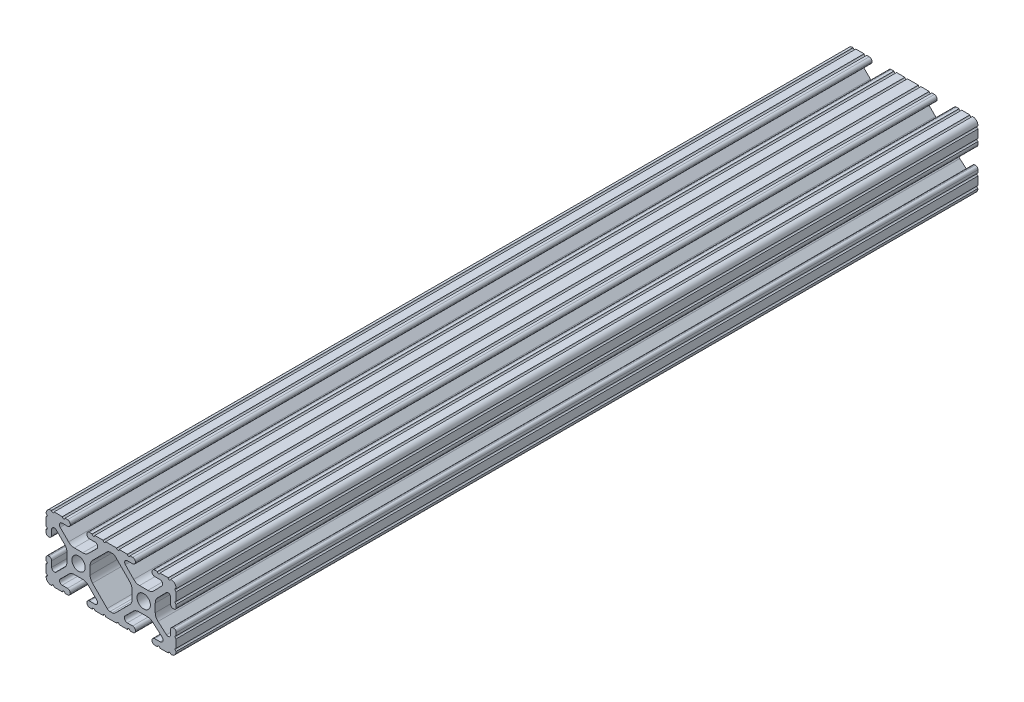
from build123d import *

# Parameters (mm, degrees)
SKETCH1_R           = 2.6035
BOSS_EXTRUDE1_DEPTH = 156.35


with BuildPart() as part:
    # Sketch1 → Boss-Extrude1 (new body, symmetric)
    with BuildSketch(Plane.XY):
        with BuildLine():
            Line((18.01710265, 12.7), (16.98745015, 12.7))
            ThreePointArc((16.98745015, 12.7), (16.245730386, 12.392769614), (15.9385, 11.65104985))
            Line((15.9385, 11.65104985), (15.9385, 11.53922))
            ThreePointArc((15.9385, 11.53922), (16.245750844, 10.797450844), (16.98752, 10.4902))
            Line((16.98752, 10.4902), (19.116384363, 10.4902))
            ThreePointArc((19.116384363, 10.4902), (20.052502933, 9.869096983), (19.844087081, 8.765172272))
            Line((19.844087081, 8.765172272), (16.618993479, 5.455112286))
            ThreePointArc((16.618993479, 5.455112286), (15.578994274, 4.745442459), (14.344932584, 4.4958))
            Line((14.344932584, 4.4958), (11.083317835, 4.4958))
            ThreePointArc((11.083317835, 4.4958), (9.854330953, 4.743306833), (8.816955189, 5.447238587))
            Line((8.816955189, 5.447238587), (5.564154119, 8.762652677))
            ThreePointArc((5.564154119, 8.762652677), (5.352591412, 9.867473037), (6.289393385, 10.4902))
            Line((6.289393385, 10.4902), (8.41248, 10.4902))
            ThreePointArc((8.41248, 10.4902), (9.154249156, 10.797450844), (9.4615, 11.53922))
            Line((9.4615, 11.53922), (9.4615, 11.65104985))
            ThreePointArc((9.4615, 11.65104985), (9.154269614, 12.392769614), (8.41254985, 12.7))
            Line((8.41254985, 12.7), (7.38288465, 12.7))
            ThreePointArc((7.38288465, 12.7), (6.87488465, 12.192), (6.36688465, 12.7))
            Line((6.36688465, 12.7), (3.14958095, 12.7))
            ThreePointArc((3.14958095, 12.7), (2.64158095, 12.192), (2.13358095, 12.7))
            Line((2.13358095, 12.7), (-2.13358095, 12.7))
            ThreePointArc((-2.13358095, 12.7), (-2.64158095, 12.192), (-3.14958095, 12.7))
            Line((-3.14958095, 12.7), (-6.36689735, 12.7))
            ThreePointArc((-6.36689735, 12.7), (-6.87489735, 12.192), (-7.38289735, 12.7))
            Line((-7.38289735, 12.7), (-8.41254985, 12.7))
            ThreePointArc((-8.41254985, 12.7), (-9.154269614, 12.392769614), (-9.4615, 11.65104985))
            Line((-9.4615, 11.65104985), (-9.4615, 11.53922))
            ThreePointArc((-9.4615, 11.53922), (-9.154249156, 10.797450844), (-8.41248, 10.4902))
            Line((-8.41248, 10.4902), (-6.283641037, 10.4902))
            ThreePointArc((-6.283641037, 10.4902), (-5.297291557, 9.829633109), (-5.532576693, 8.666071843))
            Line((-5.532576693, 8.666071843), (-8.809985098, 5.416263103))
            ThreePointArc((-8.809985098, 5.416263103), (-9.836720513, 4.734920264), (-11.045536121, 4.4958))
            Line((-11.045536121, 4.4958), (-14.354463879, 4.4958))
            ThreePointArc((-14.354463879, 4.4958), (-15.563279487, 4.734920264), (-16.590014902, 5.416263103))
            Line((-16.590014902, 5.416263103), (-19.867423307, 8.666071843))
            ThreePointArc((-19.867423307, 8.666071843), (-20.102708443, 9.829633109), (-19.116358963, 10.4902))
            Line((-19.116358963, 10.4902), (-16.98752, 10.4902))
            ThreePointArc((-16.98752, 10.4902), (-16.245750844, 10.797450844), (-15.9385, 11.53922))
            Line((-15.9385, 11.53922), (-15.9385, 11.65104985))
            ThreePointArc((-15.9385, 11.65104985), (-16.245730386, 12.392769614), (-16.98745015, 12.7))
            Line((-16.98745015, 12.7), (-18.01711535, 12.7))
            ThreePointArc((-18.01711535, 12.7), (-18.52511535, 12.192), (-19.03311535, 12.7))
            Line((-19.03311535, 12.7), (-22.2504, 12.7))
            ThreePointArc((-22.2504, 12.7), (-22.758323491, 12.192000006), (-23.266399977, 12.699846982))
            ThreePointArc((-23.266399977, 12.699846982), (-24.782522516, 12.082522516), (-25.399846982, 10.566399977))
            ThreePointArc((-25.399846982, 10.566399977), (-24.892000006, 10.058323491), (-25.4, 9.5504))
            Line((-25.4, 9.5504), (-25.4, 6.3330836))
            ThreePointArc((-25.4, 6.3330836), (-24.892, 5.8250836), (-25.4, 5.3170836))
            Line((-25.4, 5.3170836), (-25.4, 4.237520184))
            ThreePointArc((-25.4, 4.237520184), (-25.107393763, 3.531106237), (-24.400979816, 3.2385))
            Line((-24.400979816, 3.2385), (-24.23922, 3.2385))
            ThreePointArc((-24.23922, 3.2385), (-23.497450844, 3.545750844), (-23.1902, 4.28752))
            Line((-23.1902, 4.28752), (-23.1902, 6.334741132))
            ThreePointArc((-23.1902, 6.334741132), (-22.556026952, 7.286023527), (-21.434002553, 7.066535717))
            Line((-21.434002553, 7.066535717), (-18.147950853, 3.808156468))
            ThreePointArc((-18.147950853, 3.808156468), (-17.452759693, 2.774838327), (-17.208501877, 1.553619571))
            Line((-17.208501877, 1.553619571), (-17.208501877, -1.695179196))
            ThreePointArc((-17.208501877, -1.695179196), (-17.450738657, -2.911536421), (-18.140486065, -3.942289578))
            Line((-18.140486065, -3.942289578), (-21.431579576, -7.227386226))
            ThreePointArc((-21.431579576, -7.227386226), (-22.55444896, -7.449940594), (-23.1902, -6.498002195))
            Line((-23.1902, -6.498002195), (-23.1902, -4.28752))
            ThreePointArc((-23.1902, -4.28752), (-23.497450844, -3.545750844), (-24.23922, -3.2385))
            Line((-24.23922, -3.2385), (-24.35098, -3.2385))
            ThreePointArc((-24.35098, -3.2385), (-25.092749156, -3.545750844), (-25.4, -4.28752))
            Line((-25.4, -4.28752), (-25.4, -5.3171344))
            ThreePointArc((-25.4, -5.3171344), (-24.892, -5.8251344), (-25.4, -6.3331344))
            Line((-25.4, -6.3331344), (-25.4, -9.5504))
            ThreePointArc((-25.4, -9.5504), (-24.892000006, -10.058323491), (-25.399846982, -10.566399977))
            ThreePointArc((-25.399846982, -10.566399977), (-24.782522516, -12.082522516), (-23.266399977, -12.699846982))
            ThreePointArc((-23.266399977, -12.699846982), (-22.758323491, -12.192000006), (-22.2504, -12.7))
            Line((-22.2504, -12.7), (-19.03308995, -12.7))
            ThreePointArc((-19.03308995, -12.7), (-18.52508995, -12.192), (-18.01708995, -12.7))
            Line((-18.01708995, -12.7), (-16.9874692, -12.7))
            ThreePointArc((-16.9874692, -12.7), (-16.245700044, -12.392749156), (-15.9384492, -11.65098))
            Line((-15.9384492, -11.65098), (-15.9384492, -11.53922))
            ThreePointArc((-15.9384492, -11.53922), (-16.245700044, -10.797450844), (-16.9874692, -10.4902))
            Line((-16.9874692, -10.4902), (-19.116358963, -10.4902))
            ThreePointArc((-19.116358963, -10.4902), (-20.055197748, -9.862578342), (-19.834124023, -8.755124678))
            Line((-19.834124023, -8.755124678), (-16.49660751, -5.423689618))
            ThreePointArc((-16.49660751, -5.423689618), (-15.467274017, -4.736928798), (-14.253591699, -4.4958))
            Line((-14.253591699, -4.4958), (-11.146408301, -4.4958))
            ThreePointArc((-11.146408301, -4.4958), (-9.932725983, -4.736928798), (-8.90339249, -5.423689618))
            Line((-8.90339249, -5.423689618), (-5.565875977, -8.755124678))
            ThreePointArc((-5.565875977, -8.755124678), (-5.344802252, -9.862578342), (-6.283641037, -10.4902))
            Line((-6.283641037, -10.4902), (-8.4125308, -10.4902))
            ThreePointArc((-8.4125308, -10.4902), (-9.154299956, -10.797450844), (-9.4615508, -11.53922))
            Line((-9.4615508, -11.53922), (-9.4615508, -11.65098))
            ThreePointArc((-9.4615508, -11.65098), (-9.154299956, -12.392749156), (-8.4125308, -12.7))
            Line((-8.4125308, -12.7), (-7.38287195, -12.7))
            ThreePointArc((-7.38287195, -12.7), (-6.87487195, -12.192), (-6.36687195, -12.7))
            Line((-6.36687195, -12.7), (-3.14960635, -12.7))
            ThreePointArc((-3.14960635, -12.7), (-2.64160635, -12.192), (-2.13360635, -12.7))
            Line((-2.13360635, -12.7), (2.13360635, -12.7))
            ThreePointArc((2.13360635, -12.7), (2.64159365, -12.1920127), (3.14958095, -12.7))
            Line((3.14958095, -12.7), (6.36691005, -12.7))
            ThreePointArc((6.36691005, -12.7), (6.87491005, -12.192), (7.38291005, -12.7))
            Line((7.38291005, -12.7), (8.4125308, -12.7))
            ThreePointArc((8.4125308, -12.7), (9.154299956, -12.392749156), (9.4615508, -11.65098))
            Line((9.4615508, -11.65098), (9.4615508, -11.53922))
            ThreePointArc((9.4615508, -11.53922), (9.154299956, -10.797450844), (8.4125308, -10.4902))
            Line((8.4125308, -10.4902), (6.289393385, -10.4902))
            ThreePointArc((6.289393385, -10.4902), (5.231590322, -9.783049717), (5.480677245, -8.535265862))
            Line((5.480677245, -8.535265862), (8.597933595, -5.423689618))
            ThreePointArc((8.597933595, -5.423689618), (9.627267088, -4.736928798), (10.840949406, -4.4958))
            Line((10.840949406, -4.4958), (14.102564155, -4.4958))
            ThreePointArc((14.102564155, -4.4958), (15.215927525, -4.697410182), (16.187895372, -5.276636531))
            Line((16.187895372, -5.276636531), (19.868247549, -8.482246082))
            ThreePointArc((19.868247549, -8.482246082), (20.188435806, -9.746879864), (19.116384363, -10.4902))
            Line((19.116384363, -10.4902), (16.9874692, -10.4902))
            ThreePointArc((16.9874692, -10.4902), (16.245700044, -10.797450844), (15.9384492, -11.53922))
            Line((15.9384492, -11.53922), (15.9384492, -11.65098))
            ThreePointArc((15.9384492, -11.65098), (16.245700044, -12.392749156), (16.9874692, -12.7))
            Line((16.9874692, -12.7), (18.01710265, -12.7))
            ThreePointArc((18.01710265, -12.7), (18.52510265, -12.192), (19.03310265, -12.7))
            Line((19.03310265, -12.7), (22.2504, -12.7))
            ThreePointArc((22.2504, -12.7), (22.758323491, -12.192000006), (23.266399977, -12.699846982))
            ThreePointArc((23.266399977, -12.699846982), (24.782522516, -12.082522516), (25.399846982, -10.566399977))
            ThreePointArc((25.399846982, -10.566399977), (24.892000006, -10.058323492), (25.4, -9.550400001))
            Line((25.4, -9.550400001), (25.4, -6.333083592))
            ThreePointArc((25.4, -6.333083592), (24.892000001, -5.825083593), (25.4, -5.317083593))
            Line((25.4, -5.317083593), (25.4, -4.237520184))
            ThreePointArc((25.4, -4.237520184), (25.107393763, -3.531106237), (24.400979816, -3.2385))
            Line((24.400979816, -3.2385), (24.189220184, -3.2385))
            ThreePointArc((24.189220184, -3.2385), (23.482806237, -3.531106237), (23.1902, -4.237520184))
            Line((23.1902, -4.237520184), (23.1902, -6.155876159))
            ThreePointArc((23.1902, -6.155876159), (22.62232736, -7.038258539), (21.583974541, -6.886926384))
            Line((21.583974541, -6.886926384), (18.29817066, -4.024970844))
            ThreePointArc((18.29817066, -4.024970844), (17.493730985, -2.946044689), (17.208501877, -1.630807374))
            Line((17.208501877, -1.630807374), (17.208501877, 1.630807374))
            ThreePointArc((17.208501877, 1.630807374), (17.442348332, 2.82673414), (18.109440981, 3.846495088))
            Line((18.109440981, 3.846495088), (21.526346532, 7.353420386))
            ThreePointArc((21.526346532, 7.353420386), (22.585896263, 7.574939077), (23.1902, 6.676867167))
            Line((23.1902, 6.676867167), (23.1902, 4.237520184))
            ThreePointArc((23.1902, 4.237520184), (23.482806237, 3.531106237), (24.189220184, 3.2385))
            Line((24.189220184, 3.2385), (24.400979816, 3.2385))
            ThreePointArc((24.400979816, 3.2385), (25.107393763, 3.531106237), (25.4, 4.237520184))
            Line((25.4, 4.237520184), (25.4, 5.3170836))
            ThreePointArc((25.4, 5.3170836), (24.891949193, 5.825134407), (25.4, 6.333185215))
            Line((25.4, 6.333185215), (25.4, 9.550400015))
            ThreePointArc((25.4, 9.550400015), (24.892000013, 10.058323498), (25.399846982, 10.566399977))
            ThreePointArc((25.399846982, 10.566399977), (24.782522516, 12.082522516), (23.266399977, 12.699846982))
            ThreePointArc((23.266399977, 12.699846982), (22.758323491, 12.192000006), (22.2504, 12.7))
            Line((22.2504, 12.7), (19.03310265, 12.7))
            ThreePointArc((19.03310265, 12.7), (18.52510265, 12.192), (18.01710265, 12.7))
        make_face()
        with Locations((-12.7, 0)):
            Circle(SKETCH1_R, mode=Mode.SUBTRACT)
        with Locations((12.7, 0)):
            Circle(SKETCH1_R, mode=Mode.SUBTRACT)
        with BuildLine():
            Line((-7.259513935, -3.869413038), (-1.545748891, -9.572766749))
            ThreePointArc((-1.545748891, -9.572766749), (-1.035199478, -9.913400116), (-0.433213048, -10.033))
            Line((-0.433213048, -10.033), (0.433213048, -10.033))
            ThreePointArc((0.433213048, -10.033), (1.035199478, -9.913400116), (1.545748891, -9.572766749))
            Line((1.545748891, -9.572766749), (7.259513935, -3.869413038))
            ThreePointArc((7.259513935, -3.869413038), (7.949261343, -2.838659881), (8.191498123, -1.622302656))
            Line((8.191498123, -1.622302656), (8.191498123, 1.622302656))
            ThreePointArc((8.191498123, 1.622302656), (7.955573352, 2.823327967), (7.282860769, 3.845864069))
            Line((7.282860769, 3.845864069), (1.675572808, 9.561086461))
            ThreePointArc((1.675572808, 9.561086461), (1.161034429, 9.910236611), (0.551456936, 10.033))
            Line((0.551456936, 10.033), (-0.395199982, 10.033))
            ThreePointArc((-0.395199982, 10.033), (-0.994772524, 9.914396349), (-1.50403329, 9.576450301))
            Line((-1.50403329, 9.576450301), (-7.252049147, 3.876839553))
            ThreePointArc((-7.252049147, 3.876839553), (-7.947240307, 2.843521412), (-8.191498123, 1.622302656))
            Line((-8.191498123, 1.622302656), (-8.191498123, -1.622302656))
            ThreePointArc((-8.191498123, -1.622302656), (-7.949261343, -2.838659881), (-7.259513935, -3.869413038))
        make_face(mode=Mode.SUBTRACT)
    extrude(amount=BOSS_EXTRUDE1_DEPTH, both=True)


solid = part.part
